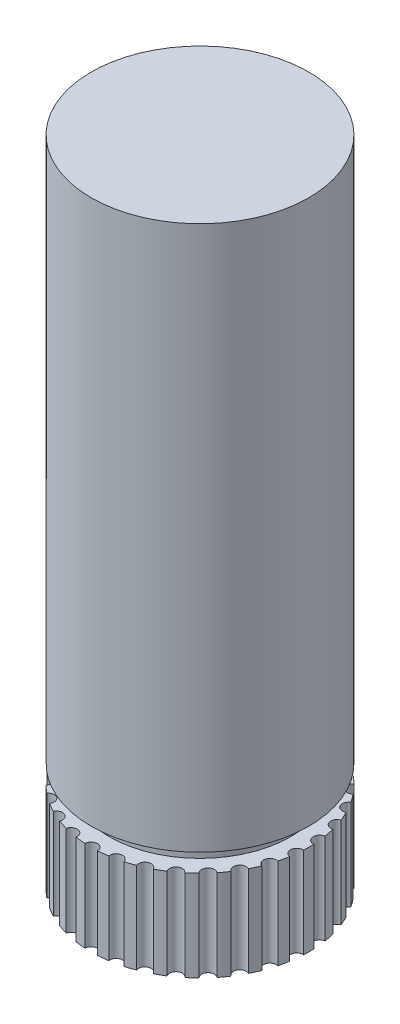
from build123d import *

# Parameters (mm, degrees)
CROQUIS1_R              = 6
SALIENTE_EXTRUIR1_DEPTH = 30
CROQUIS3_R              = 5
SALIENTE_EXTRUIR2_DEPTH = 1
CROQUIS4_R              = 6
SALIENTE_EXTRUIR3_DEPTH = 5
CROQUIS5_R              = 0.35
CORTAR_EXTRUIR1_DEPTH   = 5


with BuildPart() as part:
    # Croquis1 → Saliente-Extruir1 (new body)
    with BuildSketch(Plane(origin=(0, 0, 0), x_dir=(1, 0, 0), z_dir=(0, 1, 0))):
        Circle(CROQUIS1_R)
    extrude(amount=SALIENTE_EXTRUIR1_DEPTH)

    # Croquis3 → Saliente-Extruir2 (add)
    with BuildSketch(Plane.XZ):
        Circle(CROQUIS3_R)
    extrude(amount=SALIENTE_EXTRUIR2_DEPTH)

    # Croquis4 → Saliente-Extruir3 (add)
    with BuildSketch(Plane.XZ.offset(1)):
        Circle(CROQUIS4_R)
    extrude(amount=SALIENTE_EXTRUIR3_DEPTH)

    # Croquis5 → Cortar-Extruir1 (cut)
    with BuildSketch(Plane.XZ.offset(6)):
        with Locations((0, 6)):
            Circle(CROQUIS5_R)
        with Locations((1.247470145, 5.868885604)):
            Circle(CROQUIS5_R)
        with Locations((2.440419858, 5.481272746)):
            Circle(CROQUIS5_R)
        with Locations((3.526711514, 4.854101966)):
            Circle(CROQUIS5_R)
        with Locations((4.458868953, 4.014783638)):
            Circle(CROQUIS5_R)
        with Locations((5.196152423, 3)):
            Circle(CROQUIS5_R)
        with Locations((5.706339098, 1.854101966)):
            Circle(CROQUIS5_R)
        with Locations((5.967131372, 0.62717078)):
            Circle(CROQUIS5_R)
        with Locations((5.967131372, -0.62717078)):
            Circle(CROQUIS5_R)
        with Locations((5.706339098, -1.854101966)):
            Circle(CROQUIS5_R)
        with Locations((5.196152423, -3)):
            Circle(CROQUIS5_R)
        with Locations((4.458868953, -4.014783638)):
            Circle(CROQUIS5_R)
        with Locations((3.526711514, -4.854101966)):
            Circle(CROQUIS5_R)
        with Locations((2.440419858, -5.481272746)):
            Circle(CROQUIS5_R)
        with Locations((1.247470145, -5.868885604)):
            Circle(CROQUIS5_R)
        with Locations((0, -6)):
            Circle(CROQUIS5_R)
        with Locations((-1.247470145, -5.868885604)):
            Circle(CROQUIS5_R)
        with Locations((-2.440419858, -5.481272746)):
            Circle(CROQUIS5_R)
        with Locations((-3.526711514, -4.854101966)):
            Circle(CROQUIS5_R)
        with Locations((-4.458868953, -4.014783638)):
            Circle(CROQUIS5_R)
        with Locations((-5.196152423, -3)):
            Circle(CROQUIS5_R)
        with Locations((-5.706339098, -1.854101966)):
            Circle(CROQUIS5_R)
        with Locations((-5.967131372, -0.62717078)):
            Circle(CROQUIS5_R)
        with Locations((-5.967131372, 0.62717078)):
            Circle(CROQUIS5_R)
        with Locations((-5.706339098, 1.854101966)):
            Circle(CROQUIS5_R)
        with Locations((-5.196152423, 3)):
            Circle(CROQUIS5_R)
        with Locations((-4.458868953, 4.014783638)):
            Circle(CROQUIS5_R)
        with Locations((-3.526711514, 4.854101966)):
            Circle(CROQUIS5_R)
        with Locations((-2.440419858, 5.481272746)):
            Circle(CROQUIS5_R)
        with Locations((-1.247470145, 5.868885604)):
            Circle(CROQUIS5_R)
    extrude(amount=-CORTAR_EXTRUIR1_DEPTH, mode=Mode.SUBTRACT)


solid = part.part
